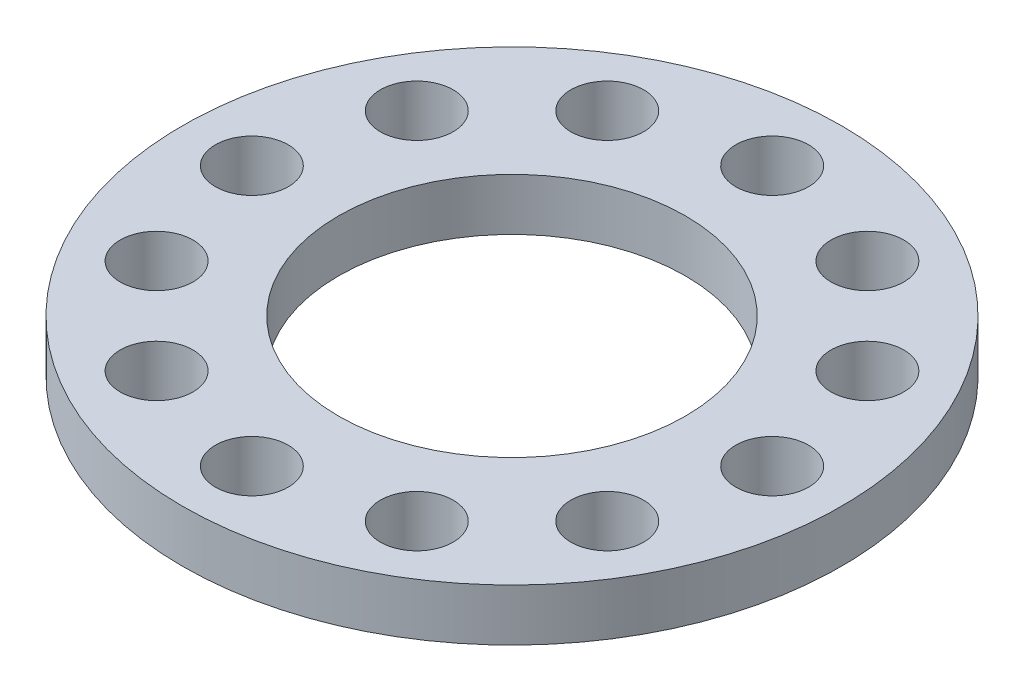
from build123d import *

# Parameters (mm, degrees)
SKETCH_1_R          = 19
EXTRUDE_1_DEPTH     = 3
CUT_EXTRUDE_1_REACH = 5
SKETCH_2_R          = 2.1
CUT_EXTRUDE_2_REACH = 5
SKETCH_3_R          = 10


with BuildPart() as part:
    # ｽｹｯﾁ1 → ﾎﾞｽ - 押し出し1 (new body)
    with BuildSketch(Plane(origin=(0, 0, 0), x_dir=(1, 0, 0), z_dir=(0, 1, 0))):
        Circle(SKETCH_1_R)
    extrude(amount=EXTRUDE_1_DEPTH)

    # ｽｹｯﾁ2 → ｶｯﾄ - 押し出し1 (cut, up to next)
    with BuildSketch(Plane(origin=(0, 3, 0), x_dir=(1, 0, 0), z_dir=(0, 1, 0)), mode=Mode.PRIVATE) as cut_extrude_1_sk1:
        with Locations((0, 15)):
            Circle(SKETCH_2_R)
    cut_extrude_1_tool1 = extrude(cut_extrude_1_sk1.sketch, amount=-CUT_EXTRUDE_1_REACH, mode=Mode.PRIVATE) & part.part
    add(cut_extrude_1_tool1.solids().sort_by_distance((0, 3, -15))[0], mode=Mode.SUBTRACT)
    # ｽｹｯﾁ2 → ｶｯﾄ - 押し出し1 (cut, up to next)
    with BuildSketch(Plane(origin=(0, 3, 0), x_dir=(1, 0, 0), z_dir=(0, 1, 0)), mode=Mode.PRIVATE) as cut_extrude_1_sk2:
        with Locations((7.5, 12.990381057)):
            Circle(SKETCH_2_R)
    cut_extrude_1_tool2 = extrude(cut_extrude_1_sk2.sketch, amount=-CUT_EXTRUDE_1_REACH, mode=Mode.PRIVATE) & part.part
    add(cut_extrude_1_tool2.solids().sort_by_distance((7.5, 3, -12.990381))[0], mode=Mode.SUBTRACT)
    # ｽｹｯﾁ2 → ｶｯﾄ - 押し出し1 (cut, up to next)
    with BuildSketch(Plane(origin=(0, 3, 0), x_dir=(1, 0, 0), z_dir=(0, 1, 0)), mode=Mode.PRIVATE) as cut_extrude_1_sk3:
        with Locations((12.990381057, 7.5)):
            Circle(SKETCH_2_R)
    cut_extrude_1_tool3 = extrude(cut_extrude_1_sk3.sketch, amount=-CUT_EXTRUDE_1_REACH, mode=Mode.PRIVATE) & part.part
    add(cut_extrude_1_tool3.solids().sort_by_distance((12.990381, 3, -7.5))[0], mode=Mode.SUBTRACT)
    # ｽｹｯﾁ2 → ｶｯﾄ - 押し出し1 (cut, up to next)
    with BuildSketch(Plane(origin=(0, 3, 0), x_dir=(1, 0, 0), z_dir=(0, 1, 0)), mode=Mode.PRIVATE) as cut_extrude_1_sk4:
        with Locations((15, 0)):
            Circle(SKETCH_2_R)
    cut_extrude_1_tool4 = extrude(cut_extrude_1_sk4.sketch, amount=-CUT_EXTRUDE_1_REACH, mode=Mode.PRIVATE) & part.part
    add(cut_extrude_1_tool4.solids().sort_by_distance((15, 3, 0))[0], mode=Mode.SUBTRACT)
    # ｽｹｯﾁ2 → ｶｯﾄ - 押し出し1 (cut, up to next)
    with BuildSketch(Plane(origin=(0, 3, 0), x_dir=(1, 0, 0), z_dir=(0, 1, 0)), mode=Mode.PRIVATE) as cut_extrude_1_sk5:
        with Locations((12.990381057, -7.5)):
            Circle(SKETCH_2_R)
    cut_extrude_1_tool5 = extrude(cut_extrude_1_sk5.sketch, amount=-CUT_EXTRUDE_1_REACH, mode=Mode.PRIVATE) & part.part
    add(cut_extrude_1_tool5.solids().sort_by_distance((12.990381, 3, 7.5))[0], mode=Mode.SUBTRACT)
    # ｽｹｯﾁ2 → ｶｯﾄ - 押し出し1 (cut, up to next)
    with BuildSketch(Plane(origin=(0, 3, 0), x_dir=(1, 0, 0), z_dir=(0, 1, 0)), mode=Mode.PRIVATE) as cut_extrude_1_sk6:
        with Locations((7.5, -12.990381057)):
            Circle(SKETCH_2_R)
    cut_extrude_1_tool6 = extrude(cut_extrude_1_sk6.sketch, amount=-CUT_EXTRUDE_1_REACH, mode=Mode.PRIVATE) & part.part
    add(cut_extrude_1_tool6.solids().sort_by_distance((7.5, 3, 12.990381))[0], mode=Mode.SUBTRACT)
    # ｽｹｯﾁ2 → ｶｯﾄ - 押し出し1 (cut, up to next)
    with BuildSketch(Plane(origin=(0, 3, 0), x_dir=(1, 0, 0), z_dir=(0, 1, 0)), mode=Mode.PRIVATE) as cut_extrude_1_sk7:
        with Locations((0, -15)):
            Circle(SKETCH_2_R)
    cut_extrude_1_tool7 = extrude(cut_extrude_1_sk7.sketch, amount=-CUT_EXTRUDE_1_REACH, mode=Mode.PRIVATE) & part.part
    add(cut_extrude_1_tool7.solids().sort_by_distance((0, 3, 15))[0], mode=Mode.SUBTRACT)
    # ｽｹｯﾁ2 → ｶｯﾄ - 押し出し1 (cut, up to next)
    with BuildSketch(Plane(origin=(0, 3, 0), x_dir=(1, 0, 0), z_dir=(0, 1, 0)), mode=Mode.PRIVATE) as cut_extrude_1_sk8:
        with Locations((-7.5, -12.990381057)):
            Circle(SKETCH_2_R)
    cut_extrude_1_tool8 = extrude(cut_extrude_1_sk8.sketch, amount=-CUT_EXTRUDE_1_REACH, mode=Mode.PRIVATE) & part.part
    add(cut_extrude_1_tool8.solids().sort_by_distance((-7.5, 3, 12.990381))[0], mode=Mode.SUBTRACT)
    # ｽｹｯﾁ2 → ｶｯﾄ - 押し出し1 (cut, up to next)
    with BuildSketch(Plane(origin=(0, 3, 0), x_dir=(1, 0, 0), z_dir=(0, 1, 0)), mode=Mode.PRIVATE) as cut_extrude_1_sk9:
        with Locations((-12.990381057, -7.5)):
            Circle(SKETCH_2_R)
    cut_extrude_1_tool9 = extrude(cut_extrude_1_sk9.sketch, amount=-CUT_EXTRUDE_1_REACH, mode=Mode.PRIVATE) & part.part
    add(cut_extrude_1_tool9.solids().sort_by_distance((-12.990381, 3, 7.5))[0], mode=Mode.SUBTRACT)
    # ｽｹｯﾁ2 → ｶｯﾄ - 押し出し1 (cut, up to next)
    with BuildSketch(Plane(origin=(0, 3, 0), x_dir=(1, 0, 0), z_dir=(0, 1, 0)), mode=Mode.PRIVATE) as cut_extrude_1_sk10:
        with Locations((-15, 0)):
            Circle(SKETCH_2_R)
    cut_extrude_1_tool10 = extrude(cut_extrude_1_sk10.sketch, amount=-CUT_EXTRUDE_1_REACH, mode=Mode.PRIVATE) & part.part
    add(cut_extrude_1_tool10.solids().sort_by_distance((-15, 3, 0))[0], mode=Mode.SUBTRACT)
    # ｽｹｯﾁ2 → ｶｯﾄ - 押し出し1 (cut, up to next)
    with BuildSketch(Plane(origin=(0, 3, 0), x_dir=(1, 0, 0), z_dir=(0, 1, 0)), mode=Mode.PRIVATE) as cut_extrude_1_sk11:
        with Locations((-12.990381057, 7.5)):
            Circle(SKETCH_2_R)
    cut_extrude_1_tool11 = extrude(cut_extrude_1_sk11.sketch, amount=-CUT_EXTRUDE_1_REACH, mode=Mode.PRIVATE) & part.part
    add(cut_extrude_1_tool11.solids().sort_by_distance((-12.990381, 3, -7.5))[0], mode=Mode.SUBTRACT)
    # ｽｹｯﾁ2 → ｶｯﾄ - 押し出し1 (cut, up to next)
    with BuildSketch(Plane(origin=(0, 3, 0), x_dir=(1, 0, 0), z_dir=(0, 1, 0)), mode=Mode.PRIVATE) as cut_extrude_1_sk12:
        with Locations((-7.5, 12.990381057)):
            Circle(SKETCH_2_R)
    cut_extrude_1_tool12 = extrude(cut_extrude_1_sk12.sketch, amount=-CUT_EXTRUDE_1_REACH, mode=Mode.PRIVATE) & part.part
    add(cut_extrude_1_tool12.solids().sort_by_distance((-7.5, 3, -12.990381))[0], mode=Mode.SUBTRACT)

    # ｽｹｯﾁ3 → ｶｯﾄ - 押し出し2 (cut, up to next)
    with BuildSketch(Plane(origin=(0, 3, 0), x_dir=(1, 0, 0), z_dir=(0, 1, 0)), mode=Mode.PRIVATE) as cut_extrude_2_sk1:
        Circle(SKETCH_3_R)
    cut_extrude_2_tool1 = extrude(cut_extrude_2_sk1.sketch, amount=-CUT_EXTRUDE_2_REACH, mode=Mode.PRIVATE) & part.part
    add(cut_extrude_2_tool1.solids().sort_by_distance((0, 3, 0))[0], mode=Mode.SUBTRACT)


solid = part.part
